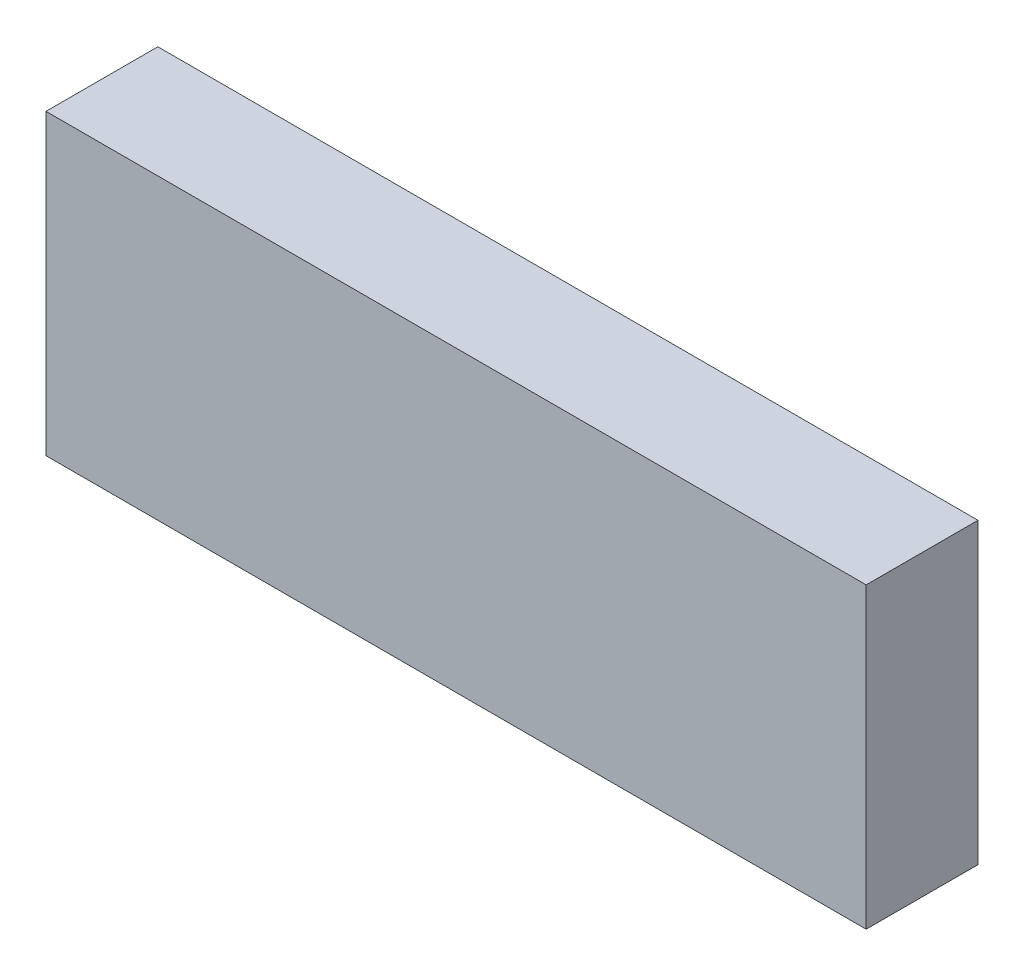
from build123d import *

# Parameters (mm, degrees)
SKETCH1_W           = 22
SKETCH1_H           = 8
BOSS_EXTRUDE1_DEPTH = 3


with BuildPart() as part:
    # Sketch1 → Boss-Extrude1 (new body)
    with BuildSketch(Plane.XY):
        with Locations((4, 3.5)):
            Rectangle(SKETCH1_W, SKETCH1_H)
    extrude(amount=BOSS_EXTRUDE1_DEPTH)


solid = part.part
